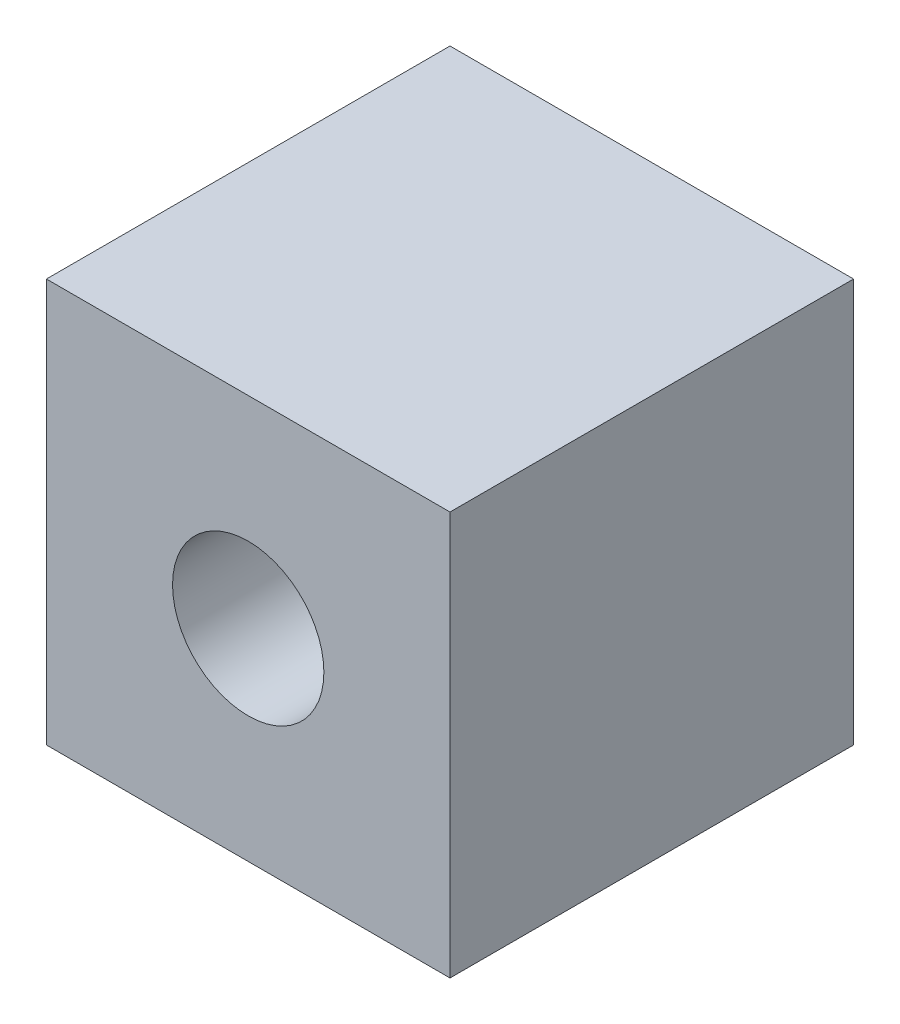
from build123d import *

# Parameters (mm, degrees)
SKETCH1_W           = 1016.002032004
SKETCH1_H           = 1016.002032004
BOSS_EXTRUDE1_DEPTH = 508
SKETCH2_R           = 190.500381001
CUT_EXTRUDE1_DEPTH  = 1017


with BuildPart() as part:
    # Sketch1 → Boss-Extrude1 (new body, symmetric)
    with BuildSketch(Plane.XY):
        Rectangle(SKETCH1_W, SKETCH1_H)
    extrude(amount=BOSS_EXTRUDE1_DEPTH, both=True)

    # Sketch2 → Cut-Extrude1 (cut, through all)
    with BuildSketch(Plane.XY.offset(508)):
        Circle(SKETCH2_R)
    extrude(amount=-CUT_EXTRUDE1_DEPTH, mode=Mode.SUBTRACT)


solid = part.part
